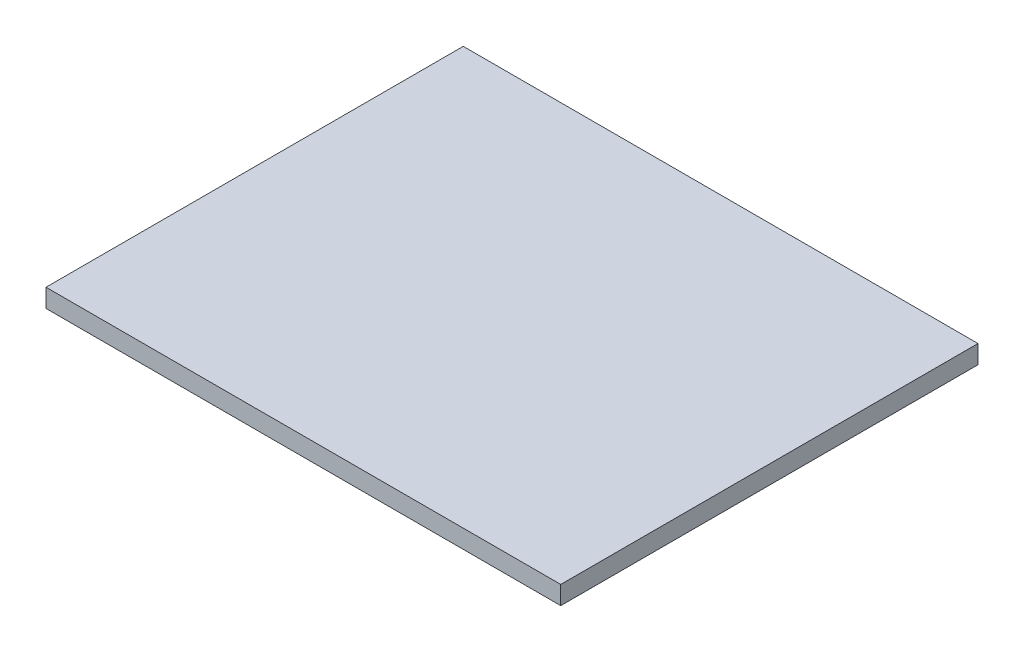
from build123d import *

# Parameters (mm, degrees)
SKETCH1_W           = 83.919193497
SKETCH1_H           = 68.024782952
BOSS_EXTRUDE1_DEPTH = 3


with BuildPart() as part:
    # Sketch1 → Boss-Extrude1 (new body)
    with BuildSketch(Plane(origin=(0, 0, 0), x_dir=(1, 0, 0), z_dir=(0, 1, 0))):
        with Locations((41.959596749, 34.012391476)):
            Rectangle(SKETCH1_W, SKETCH1_H)
    extrude(amount=BOSS_EXTRUDE1_DEPTH)


solid = part.part
